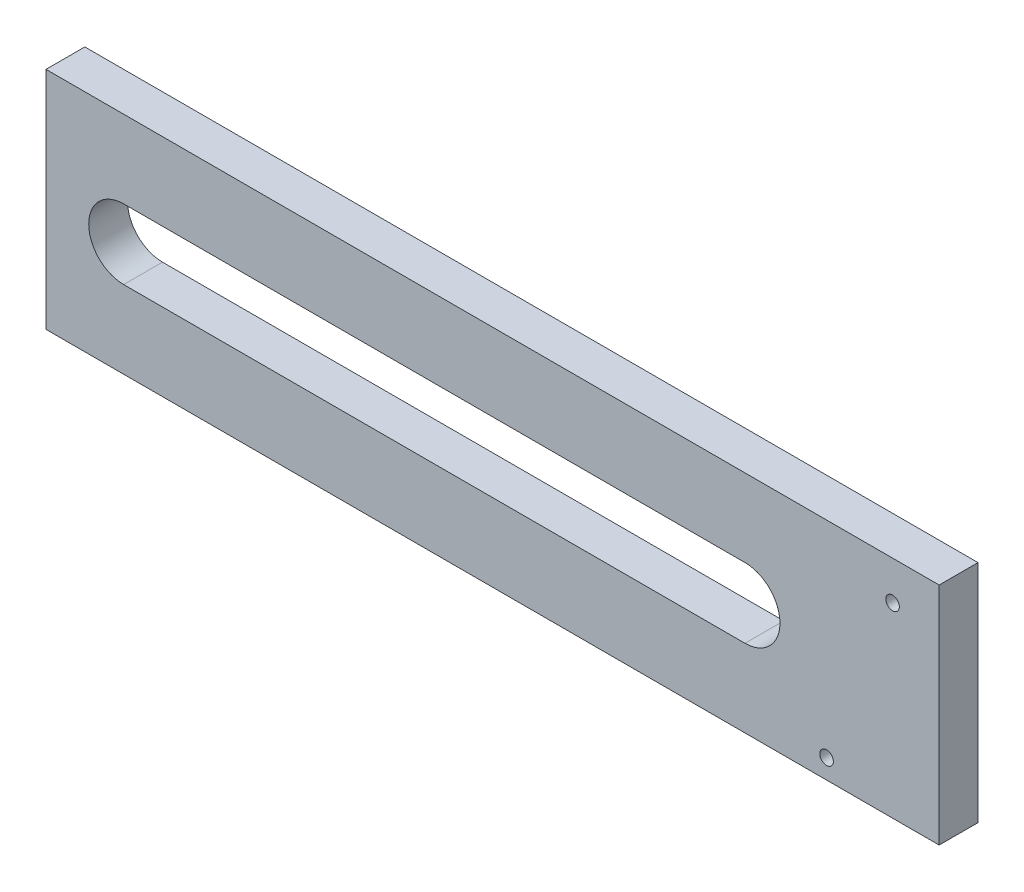
from build123d import *

# Parameters (mm, degrees)
ESQUISSE1_W        = 230
ESQUISSE1_H        = 58
ESQUISSE1_R        = 1.75
BOSS_EXTRU_1_DEPTH = 10


with BuildPart() as part:
    # Esquisse1 → Boss.-Extru.1 (new body)
    with BuildSketch(Plane.XY):
        with Locations((-19.287380446, 0.978440775)):
            Rectangle(ESQUISSE1_W, ESQUISSE1_H)
        with Locations((83.712619554, 19.978440775)):
            Circle(ESQUISSE1_R, mode=Mode.SUBTRACT)
        with Locations((66.712619554, -23.021559225)):
            Circle(ESQUISSE1_R, mode=Mode.SUBTRACT)
        with BuildLine():
            Line((-114.287380446, 9.978440775), (45.712619554, 9.978440775))
            ThreePointArc((45.712619554, 9.978440775), (54.712619554, 0.978440775), (45.712619554, -8.021559225))
            Line((45.712619554, -8.021559225), (-114.287380446, -8.021559225))
            ThreePointArc((-114.287380446, -8.021559225), (-123.287380446, 0.978440775), (-114.287380446, 9.978440775))
        make_face(mode=Mode.SUBTRACT)
    extrude(amount=BOSS_EXTRU_1_DEPTH)


solid = part.part
